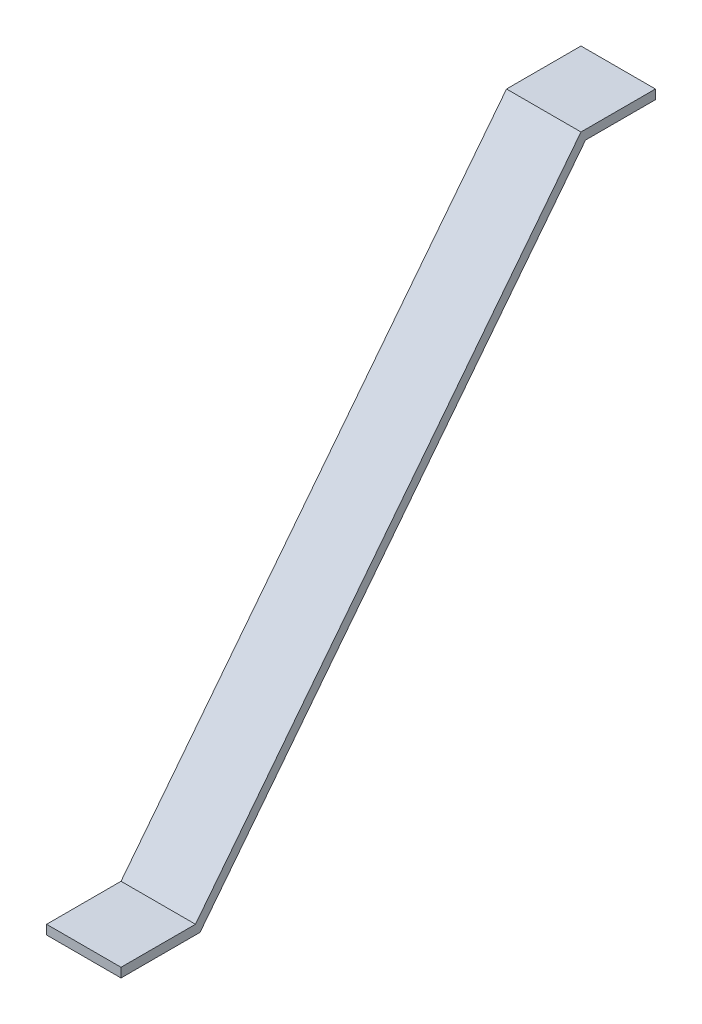
from build123d import *

# Parameters (mm, degrees)
BOSS_EXTRUDE1_DEPTH = 25.4


with BuildPart() as part:
    # Sketch1 → Boss-Extrude1 (new body)
    with BuildSketch(Plane(origin=(0, 0, 0), x_dir=(0, 0, -1), z_dir=(1, 0, 0))):
        Polygon((-122.456620816, -14.03991021), (-97.056620816, -14.03991021), (34.448670314, 154.279186761), (59.848670314, 154.279186761), (59.848670314, 151.104186761), (35.997221283, 151.104186761), (-95.508069847, -17.21491021), (-122.456620816, -17.21491021), align=None)
    extrude(amount=BOSS_EXTRUDE1_DEPTH)


solid = part.part
